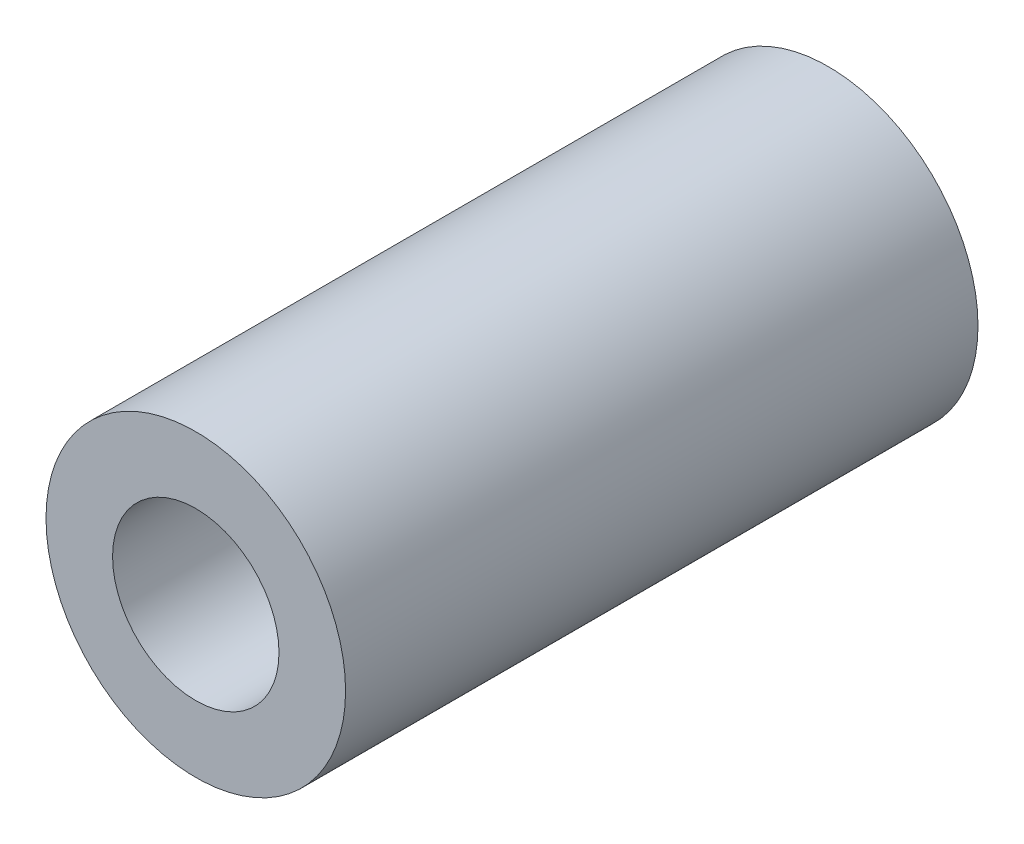
from build123d import *

# Parameters (mm, degrees)
SKETCH1_R           = 4.5
SKETCH1_R_2         = 2.5
BOSS_EXTRUDE1_DEPTH = 19


with BuildPart() as part:
    # Sketch1 → Boss-Extrude1 (new body)
    with BuildSketch(Plane.XY):
        Circle(SKETCH1_R)
        Circle(SKETCH1_R_2, mode=Mode.SUBTRACT)
    extrude(amount=BOSS_EXTRUDE1_DEPTH)


solid = part.part
